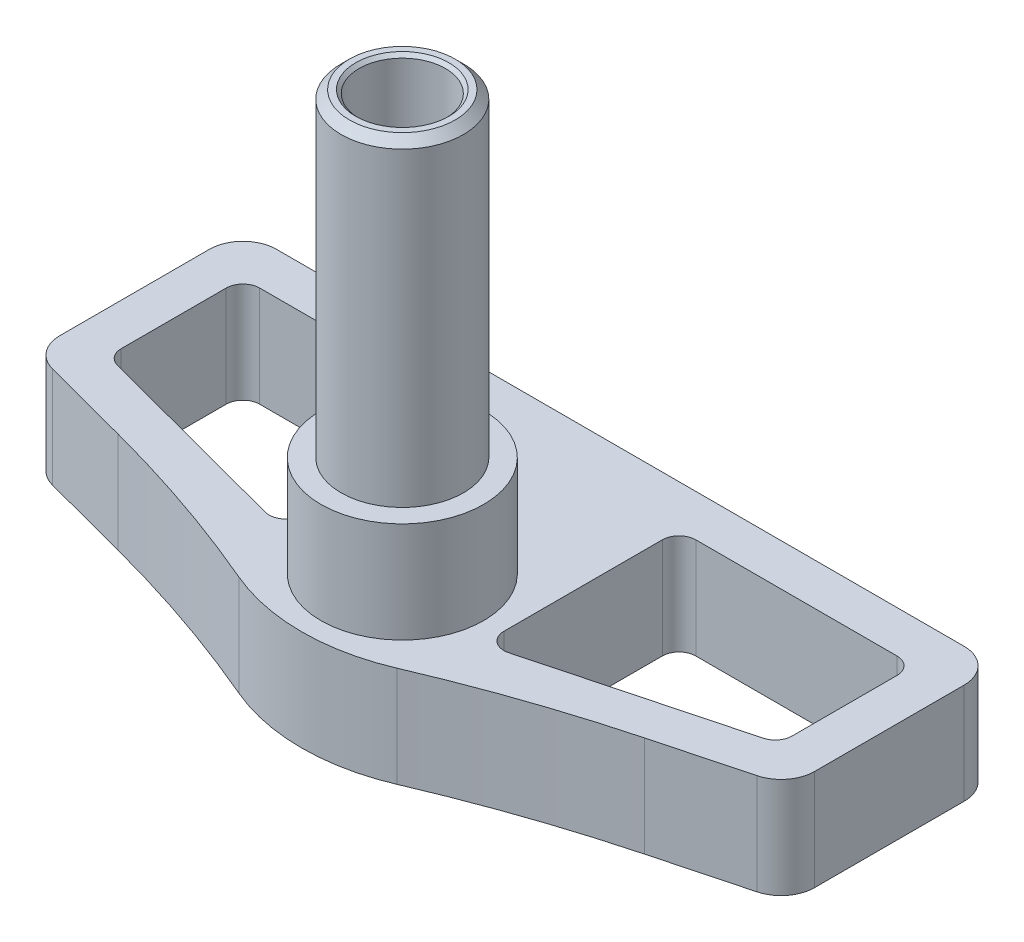
from build123d import *

# Parameters (mm, degrees)
SKETCH2_W               = 45
SKETCH2_H               = 70
SKETCH2_W_2             = 25
SKETCH2_H_2             = 50
BOSS_EXTRUDE2_DEPTH     = 10
CUT_EXTRUDE1_REACH      = 72
BOSS_EXTRUDE3_DEPTH     = 10
SKETCH6_R               = 3.65
BOSS_EXTRUDE4_DEPTH     = 16
BOSS_EXTRUDE5_DEPTH     = 10
BOSS_EXTRUDE8_DEPTH     = 8
SKETCH9_W               = 6
SKETCH9_H               = 16.4
CUT_EXTRUDE2_DEPTH      = 6
CUT_EXTRUDE3_DEPTH      = 15.5
CUT_EXTRUDE3_DEPTH_BACK = 31.5
SKETCH11_W              = 63.799799384
SKETCH11_H              = 31.786722146
CUT_EXTRUDE4_DEPTH      = 77
SKETCH12_R              = 3.65
BOSS_EXTRUDE9_DEPTH     = 21
SKETCH13_R              = 4.85
SKETCH13_R_2            = 3.65
BOSS_EXTRUDE10_DEPTH    = 2
SKETCH14_R              = 4.85
CUT_EXTRUDE6_DEPTH      = 4
CUT_EXTRUDE7_DEPTH      = 7
FILLET1_R               = 1
SKETCH16_R              = 2.575
CUT_EXTRUDE8_DEPTH      = 13.5
CHAMFER1_SIZE           = 0.5
CHAMFER2_SIZE           = 0.2
SKETCH17_R              = 2.4
CUT_EXTRUDE9_DEPTH      = 12
FILLET2_R               = 2


with BuildPart() as part:
    # Sketch2 → Boss-Extrude2 (new body)
    with BuildSketch(Plane.XY):
        with Locations((0, 35)):
            Rectangle(SKETCH2_W, SKETCH2_H)
        with Locations((0, 35)):
            Rectangle(SKETCH2_W_2, SKETCH2_H_2, mode=Mode.SUBTRACT)
    extrude(amount=BOSS_EXTRUDE2_DEPTH)

    # Sketch3 → Cut-Extrude1 (cut, up to next)
    with BuildSketch(Plane(origin=(0, 70, 0), x_dir=(1, 0, 0), z_dir=(0, 1, 0)), mode=Mode.PRIVATE) as cut_extrude1_sk1:
        Polygon((-12, 0), (-12, -4), (-5, -4), (-5, -8), (5, -8), (5, -4), (12, -4), (12, 0), align=None)
    cut_extrude1_tool1 = extrude(cut_extrude1_sk1.sketch, amount=-CUT_EXTRUDE1_REACH, mode=Mode.PRIVATE) & part.part
    add(cut_extrude1_tool1.solids().sort_by_distance((0, 70, 3.176471))[0], mode=Mode.SUBTRACT)

    # Sketch4 → Boss-Extrude3 (add)
    with BuildSketch(Plane(origin=(0, 70, 0), x_dir=(1, 0, 0), z_dir=(0, 1, 0))):
        with BuildLine():
            Line((-12, -10), (12, -10))
            ThreePointArc((12, -10), (7.5, -11.5), (4.8, -15.4))
            ThreePointArc((4.8, -15.4), (0, -19), (-4.8, -15.4))
            ThreePointArc((-4.8, -15.4), (-7.5, -11.5), (-12, -10))
        make_face()
    extrude(amount=-BOSS_EXTRUDE3_DEPTH)

    # Sketch6 → Boss-Extrude4 (add)
    with BuildSketch(Plane(origin=(0, 70, 0), x_dir=(1, 0, 0), z_dir=(0, 1, 0))):
        with Locations((0, -13)):
            Circle(SKETCH6_R)
    extrude(amount=BOSS_EXTRUDE4_DEPTH)

    # Sketch7 → Boss-Extrude5 (add)
    with BuildSketch(Plane.XZ):
        with BuildLine():
            Line((-22.5, 10), (-22.5, 12.456100996))
            Line((-22.5, 12.456100996), (-15.693142744, 14.258664405))
            ThreePointArc((-15.693142744, 14.258664405), (-10.135286431, 15.948047702), (-4.714257706, 18.035206128))
            ThreePointArc((-4.714257706, 18.035206128), (0, 19), (4.714257706, 18.035206128))
            ThreePointArc((4.714257706, 18.035206128), (10.135286431, 15.948047702), (15.693142744, 14.258664405))
            Line((15.693142744, 14.258664405), (22.5, 12.456100996))
            Line((22.5, 12.456100996), (22.5, 10))
            Line((22.5, 10), (-22.5, 10))
        make_face()
    extrude(amount=-BOSS_EXTRUDE5_DEPTH)

    # Sketch8 → Boss-Extrude8 (add, symmetric)
    with BuildSketch(Plane(origin=(0, 0, 0), x_dir=(0, 0, -1), z_dir=(1, 0, 0))):
        Polygon((-19, 66.9), (-23, 66.9), (-23, 50.5), (-19.5, 50.5), (-10, 60), (-10, 66.9), align=None)
    extrude(amount=BOSS_EXTRUDE8_DEPTH, both=True)

    # Sketch9 → Cut-Extrude2 (cut)
    with BuildSketch(Plane.XY.offset(23)):
        with Locations((0, 58.7)):
            Rectangle(SKETCH9_W, SKETCH9_H)
    extrude(amount=-CUT_EXTRUDE2_DEPTH, mode=Mode.SUBTRACT)

    # Sketch10 → Cut-Extrude3 (cut, two sides)
    with BuildSketch(Plane.ZY.offset(8)) as cut_extrude3_sk:
        with BuildLine():
            Line((18.35, 64.4), (18.35, 54.4))
            ThreePointArc((18.35, 54.4), (20, 52.75), (21.65, 54.4))
            Line((21.65, 54.4), (21.65, 64.4))
            ThreePointArc((21.65, 64.4), (20, 66.05), (18.35, 64.4))
        make_face()
    extrude(amount=CUT_EXTRUDE3_DEPTH, mode=Mode.SUBTRACT)
    extrude(cut_extrude3_sk.sketch, amount=-CUT_EXTRUDE3_DEPTH_BACK, mode=Mode.SUBTRACT)

    # Sketch11 → Cut-Extrude4 (cut, through all)
    with BuildSketch(Plane(origin=(0, 10, 0), x_dir=(1, 0, 0), z_dir=(0, 1, 0))):
        with Locations((-0.274859754, -9.346463675)):
            Rectangle(SKETCH11_W, SKETCH11_H)
    extrude(amount=CUT_EXTRUDE4_DEPTH, mode=Mode.SUBTRACT)

    # Sketch12 → Boss-Extrude9 (add)
    with BuildSketch(Plane(origin=(0, 10, 0), x_dir=(1, 0, 0), z_dir=(0, 1, 0))):
        with Locations((0, -13)):
            Circle(SKETCH12_R)
    extrude(amount=BOSS_EXTRUDE9_DEPTH)

    # Sketch13 → Boss-Extrude10 (add)
    with BuildSketch(Plane(origin=(0, 10, 0), x_dir=(1, 0, 0), z_dir=(0, 1, 0))):
        with Locations((0, -13)):
            Circle(SKETCH13_R)
        with Locations((0, -13)):
            Circle(SKETCH13_R_2, mode=Mode.SUBTRACT)
    extrude(amount=BOSS_EXTRUDE10_DEPTH)

    # Sketch14 → Cut-Extrude6 (cut)
    with BuildSketch(Plane(origin=(0, 10, 0), x_dir=(1, 0, 0), z_dir=(0, 1, 0))):
        with BuildLine():
            Line((22.5, -12.456100996), (22.5, 0))
            Line((22.5, 0), (-22.5, 0))
            Line((-22.5, 0), (-22.5, -12.456100996))
            Line((-22.5, -12.456100996), (-15.693142744, -14.258664405))
            ThreePointArc((-15.693142744, -14.258664405), (-10.135286431, -15.948047702), (-4.714257706, -18.035206128))
            ThreePointArc((-4.714257706, -18.035206128), (0, -19), (4.714257706, -18.035206128))
            ThreePointArc((4.714257706, -18.035206128), (10.135286431, -15.948047702), (15.693142744, -14.258664405))
            Line((15.693142744, -14.258664405), (22.5, -12.456100996))
        make_face()
        with Locations((0, -13)):
            Circle(SKETCH14_R, mode=Mode.SUBTRACT)
    extrude(amount=-CUT_EXTRUDE6_DEPTH, mode=Mode.SUBTRACT)

    # Sketch15 → Cut-Extrude7 (cut, through all)
    with BuildSketch(Plane(origin=(0, 6, 0), x_dir=(1, 0, 0), z_dir=(0, 1, 0))):
        Polygon((6, -2.5), (20, -2.5), (20, -10.531966446), (6, -14.239387769), align=None)
        Polygon((-6, -14.239387769), (-6, -2.5), (-20, -2.5), (-20, -10.531966446), align=None)
    extrude(amount=-CUT_EXTRUDE7_DEPTH, mode=Mode.SUBTRACT)

    # Fillet1
    fillet1_edges = [part.edges().sort_by_distance(p)[0] for p in [
        (20, 3, 2.5),
        (20, 3, 10.531966446),
        (6, 3, 14.239387769),
        (6, 3, 2.5),
        (-6, 3, 14.239387769),
        (-20, 3, 10.531966446),
        (-20, 3, 2.5),
        (-6, 3, 2.5),
    ]]
    fillet(fillet1_edges, radius=FILLET1_R)

    # Sketch16 → Cut-Extrude8 (cut)
    with BuildSketch(Plane(origin=(0, 31, 0), x_dir=(1, 0, 0), z_dir=(0, 1, 0))):
        with Locations((0, -13)):
            Circle(SKETCH16_R)
    extrude(amount=-CUT_EXTRUDE8_DEPTH, mode=Mode.SUBTRACT)

    # Chamfer1
    chamfer1_edges = [part.edges().sort_by_distance(p)[0] for p in [
        (-3.65, 31, 13),
    ]]
    chamfer(chamfer1_edges, length=CHAMFER1_SIZE)

    # Chamfer2
    chamfer2_edges = [part.edges().sort_by_distance(p)[0] for p in [
        (-2.575, 31, 13),
    ]]
    chamfer(chamfer2_edges, length=CHAMFER2_SIZE)

    # Sketch17 → Cut-Extrude9 (cut)
    with BuildSketch(Plane(origin=(0, 17.5, 0), x_dir=(1, 0, 0), z_dir=(0, 1, 0))):
        with Locations((0, -13)):
            Circle(SKETCH17_R)
    extrude(amount=-CUT_EXTRUDE9_DEPTH, mode=Mode.SUBTRACT)

    # Fillet2
    fillet2_edges = [part.edges().sort_by_distance(p)[0] for p in [
        (-22.5, 3, 12.456100996),
        (22.5, 3, 12.456100996),
        (-22.5, 3, 0),
        (22.5, 3, 0),
    ]]
    fillet(fillet2_edges, radius=FILLET2_R)


solid = part.part
